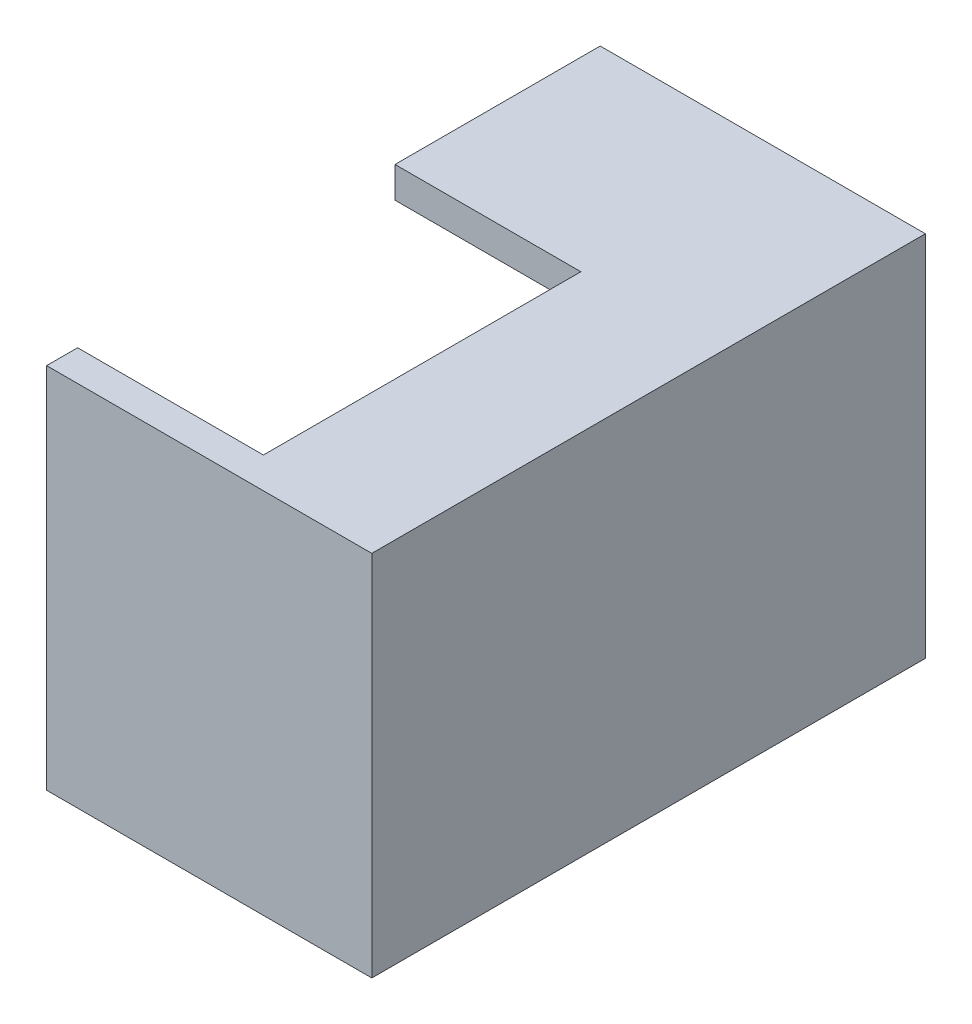
from build123d import *

# Parameters (mm, degrees)
SKETCH4_W           = 31.75
SKETCH4_H           = 19.75
BOSS_EXTRUDE1_DEPTH = 19
SHELL1_T            = 2
SKETCH5_W           = 12
SKETCH5_H           = 20.5
CUT_EXTRUDE1_DEPTH  = 2


with BuildPart() as part:
    # Sketch4 → Boss-Extrude1 (new body)
    with BuildSketch(Plane(origin=(0, 0, 0), x_dir=(0, 0, -1), z_dir=(1, 0, 0))):
        Rectangle(SKETCH4_W, SKETCH4_H)
    extrude(amount=BOSS_EXTRUDE1_DEPTH)

    # Shell1
    shell1_openings = [part.faces().sort_by_distance(p)[0] for p in [
        (0, 0, 0),
    ]]
    offset(amount=SHELL1_T, openings=shell1_openings, kind=Kind.INTERSECTION)

    # Sketch5 → Cut-Extrude1 (cut)
    with BuildSketch(Plane(origin=(0, 11.875, 0), x_dir=(1, 0, 0), z_dir=(0, 1, 0))):
        with Locations((6, -5.625)):
            Rectangle(SKETCH5_W, SKETCH5_H)
    extrude(amount=-CUT_EXTRUDE1_DEPTH, mode=Mode.SUBTRACT)


solid = part.part
